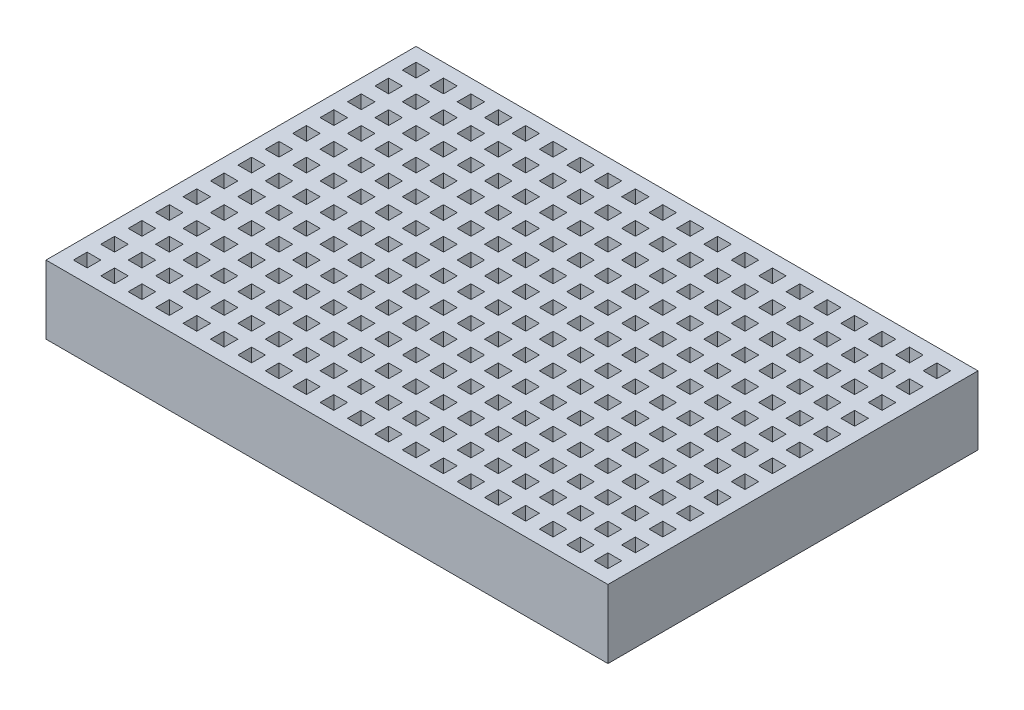
from build123d import *

# Parameters (mm, degrees)
SKETCH1_W           = 82
SKETCH1_H           = 54
BOSS_EXTRUDE2_DEPTH = 10
SKETCH3_W           = 2
SKETCH3_H           = 2
CUT_EXTRUDE1_DEPTH  = 5


with BuildPart() as part:
    # Sketch1 → Boss-Extrude2 (new body)
    with BuildSketch(Plane(origin=(0, 0, 0), x_dir=(1, 0, 0), z_dir=(0, 1, 0))):
        with Locations((-3.830449827, -8.982698962)):
            Rectangle(SKETCH1_W, SKETCH1_H)
    extrude(amount=BOSS_EXTRUDE2_DEPTH)

    # Sketch3 → Cut-Extrude1 (cut)
    with BuildSketch(Plane(origin=(0, 10, 0), x_dir=(1, 0, 0), z_dir=(0, 1, 0))):
        with Locations((-41.830449827, 15.017301038)):
            Rectangle(SKETCH3_W, SKETCH3_H)
        with Locations((-37.830449827, 15.017301038)):
            Rectangle(SKETCH3_W, SKETCH3_H)
        with Locations((-33.830449827, 15.017301038)):
            Rectangle(SKETCH3_W, SKETCH3_H)
        with Locations((-29.830449827, 15.017301038)):
            Rectangle(SKETCH3_W, SKETCH3_H)
        with Locations((-25.830449827, 15.017301038)):
            Rectangle(SKETCH3_W, SKETCH3_H)
        with Locations((-21.830449827, 15.017301038)):
            Rectangle(SKETCH3_W, SKETCH3_H)
        with Locations((-17.830449827, 15.017301038)):
            Rectangle(SKETCH3_W, SKETCH3_H)
        with Locations((-13.830449827, 15.017301038)):
            Rectangle(SKETCH3_W, SKETCH3_H)
        with Locations((-9.830449827, 15.017301038)):
            Rectangle(SKETCH3_W, SKETCH3_H)
        with Locations((-5.830449827, 15.017301038)):
            Rectangle(SKETCH3_W, SKETCH3_H)
        with Locations((-1.830449827, 15.017301038)):
            Rectangle(SKETCH3_W, SKETCH3_H)
        with Locations((2.169550173, 15.017301038)):
            Rectangle(SKETCH3_W, SKETCH3_H)
        with Locations((6.169550173, 15.017301038)):
            Rectangle(SKETCH3_W, SKETCH3_H)
        with Locations((10.169550173, 15.017301038)):
            Rectangle(SKETCH3_W, SKETCH3_H)
        with Locations((14.169550173, 15.017301038)):
            Rectangle(SKETCH3_W, SKETCH3_H)
        with Locations((18.169550173, 15.017301038)):
            Rectangle(SKETCH3_W, SKETCH3_H)
        with Locations((22.169550173, 15.017301038)):
            Rectangle(SKETCH3_W, SKETCH3_H)
        with Locations((26.169550173, 15.017301038)):
            Rectangle(SKETCH3_W, SKETCH3_H)
        with Locations((30.169550173, 15.017301038)):
            Rectangle(SKETCH3_W, SKETCH3_H)
        with Locations((34.169550173, 15.017301038)):
            Rectangle(SKETCH3_W, SKETCH3_H)
        with Locations((-37.830449827, 11.017301038)):
            Rectangle(SKETCH3_W, SKETCH3_H)
        with Locations((-33.830449827, 11.017301038)):
            Rectangle(SKETCH3_W, SKETCH3_H)
        with Locations((-29.830449827, 11.017301038)):
            Rectangle(SKETCH3_W, SKETCH3_H)
        with Locations((-25.830449827, 11.017301038)):
            Rectangle(SKETCH3_W, SKETCH3_H)
        with Locations((-21.830449827, 11.017301038)):
            Rectangle(SKETCH3_W, SKETCH3_H)
        with Locations((-17.830449827, 11.017301038)):
            Rectangle(SKETCH3_W, SKETCH3_H)
        with Locations((-13.830449827, 11.017301038)):
            Rectangle(SKETCH3_W, SKETCH3_H)
        with Locations((-9.830449827, 11.017301038)):
            Rectangle(SKETCH3_W, SKETCH3_H)
        with Locations((-5.830449827, 11.017301038)):
            Rectangle(SKETCH3_W, SKETCH3_H)
        with Locations((-1.830449827, 11.017301038)):
            Rectangle(SKETCH3_W, SKETCH3_H)
        with Locations((2.169550173, 11.017301038)):
            Rectangle(SKETCH3_W, SKETCH3_H)
        with Locations((6.169550173, 11.017301038)):
            Rectangle(SKETCH3_W, SKETCH3_H)
        with Locations((10.169550173, 11.017301038)):
            Rectangle(SKETCH3_W, SKETCH3_H)
        with Locations((14.169550173, 11.017301038)):
            Rectangle(SKETCH3_W, SKETCH3_H)
        with Locations((18.169550173, 11.017301038)):
            Rectangle(SKETCH3_W, SKETCH3_H)
        with Locations((22.169550173, 11.017301038)):
            Rectangle(SKETCH3_W, SKETCH3_H)
        with Locations((26.169550173, 11.017301038)):
            Rectangle(SKETCH3_W, SKETCH3_H)
        with Locations((30.169550173, 11.017301038)):
            Rectangle(SKETCH3_W, SKETCH3_H)
        with Locations((34.169550173, 11.017301038)):
            Rectangle(SKETCH3_W, SKETCH3_H)
        with Locations((-37.830449827, 7.017301038)):
            Rectangle(SKETCH3_W, SKETCH3_H)
        with Locations((-33.830449827, 7.017301038)):
            Rectangle(SKETCH3_W, SKETCH3_H)
        with Locations((-29.830449827, 7.017301038)):
            Rectangle(SKETCH3_W, SKETCH3_H)
        with Locations((-25.830449827, 7.017301038)):
            Rectangle(SKETCH3_W, SKETCH3_H)
        with Locations((-21.830449827, 7.017301038)):
            Rectangle(SKETCH3_W, SKETCH3_H)
        with Locations((-17.830449827, 7.017301038)):
            Rectangle(SKETCH3_W, SKETCH3_H)
        with Locations((-13.830449827, 7.017301038)):
            Rectangle(SKETCH3_W, SKETCH3_H)
        with Locations((-9.830449827, 7.017301038)):
            Rectangle(SKETCH3_W, SKETCH3_H)
        with Locations((-5.830449827, 7.017301038)):
            Rectangle(SKETCH3_W, SKETCH3_H)
        with Locations((-1.830449827, 7.017301038)):
            Rectangle(SKETCH3_W, SKETCH3_H)
        with Locations((2.169550173, 7.017301038)):
            Rectangle(SKETCH3_W, SKETCH3_H)
        with Locations((6.169550173, 7.017301038)):
            Rectangle(SKETCH3_W, SKETCH3_H)
        with Locations((10.169550173, 7.017301038)):
            Rectangle(SKETCH3_W, SKETCH3_H)
        with Locations((14.169550173, 7.017301038)):
            Rectangle(SKETCH3_W, SKETCH3_H)
        with Locations((18.169550173, 7.017301038)):
            Rectangle(SKETCH3_W, SKETCH3_H)
        with Locations((22.169550173, 7.017301038)):
            Rectangle(SKETCH3_W, SKETCH3_H)
        with Locations((26.169550173, 7.017301038)):
            Rectangle(SKETCH3_W, SKETCH3_H)
        with Locations((30.169550173, 7.017301038)):
            Rectangle(SKETCH3_W, SKETCH3_H)
        with Locations((34.169550173, 7.017301038)):
            Rectangle(SKETCH3_W, SKETCH3_H)
        with Locations((-37.830449827, 3.017301038)):
            Rectangle(SKETCH3_W, SKETCH3_H)
        with Locations((-33.830449827, 3.017301038)):
            Rectangle(SKETCH3_W, SKETCH3_H)
        with Locations((-29.830449827, 3.017301038)):
            Rectangle(SKETCH3_W, SKETCH3_H)
        with Locations((-25.830449827, 3.017301038)):
            Rectangle(SKETCH3_W, SKETCH3_H)
        with Locations((-21.830449827, 3.017301038)):
            Rectangle(SKETCH3_W, SKETCH3_H)
        with Locations((-17.830449827, 3.017301038)):
            Rectangle(SKETCH3_W, SKETCH3_H)
        with Locations((-13.830449827, 3.017301038)):
            Rectangle(SKETCH3_W, SKETCH3_H)
        with Locations((-9.830449827, 3.017301038)):
            Rectangle(SKETCH3_W, SKETCH3_H)
        with Locations((-5.830449827, 3.017301038)):
            Rectangle(SKETCH3_W, SKETCH3_H)
        with Locations((-1.830449827, 3.017301038)):
            Rectangle(SKETCH3_W, SKETCH3_H)
        with Locations((2.169550173, 3.017301038)):
            Rectangle(SKETCH3_W, SKETCH3_H)
        with Locations((6.169550173, 3.017301038)):
            Rectangle(SKETCH3_W, SKETCH3_H)
        with Locations((10.169550173, 3.017301038)):
            Rectangle(SKETCH3_W, SKETCH3_H)
        with Locations((14.169550173, 3.017301038)):
            Rectangle(SKETCH3_W, SKETCH3_H)
        with Locations((18.169550173, 3.017301038)):
            Rectangle(SKETCH3_W, SKETCH3_H)
        with Locations((22.169550173, 3.017301038)):
            Rectangle(SKETCH3_W, SKETCH3_H)
        with Locations((26.169550173, 3.017301038)):
            Rectangle(SKETCH3_W, SKETCH3_H)
        with Locations((30.169550173, 3.017301038)):
            Rectangle(SKETCH3_W, SKETCH3_H)
        with Locations((34.169550173, 3.017301038)):
            Rectangle(SKETCH3_W, SKETCH3_H)
        with Locations((-37.830449827, -0.982698962)):
            Rectangle(SKETCH3_W, SKETCH3_H)
        with Locations((-33.830449827, -0.982698962)):
            Rectangle(SKETCH3_W, SKETCH3_H)
        with Locations((-29.830449827, -0.982698962)):
            Rectangle(SKETCH3_W, SKETCH3_H)
        with Locations((-25.830449827, -0.982698962)):
            Rectangle(SKETCH3_W, SKETCH3_H)
        with Locations((-21.830449827, -0.982698962)):
            Rectangle(SKETCH3_W, SKETCH3_H)
        with Locations((-17.830449827, -0.982698962)):
            Rectangle(SKETCH3_W, SKETCH3_H)
        with Locations((-13.830449827, -0.982698962)):
            Rectangle(SKETCH3_W, SKETCH3_H)
        with Locations((-9.830449827, -0.982698962)):
            Rectangle(SKETCH3_W, SKETCH3_H)
        with Locations((-5.830449827, -0.982698962)):
            Rectangle(SKETCH3_W, SKETCH3_H)
        with Locations((-1.830449827, -0.982698962)):
            Rectangle(SKETCH3_W, SKETCH3_H)
        with Locations((2.169550173, -0.982698962)):
            Rectangle(SKETCH3_W, SKETCH3_H)
        with Locations((6.169550173, -0.982698962)):
            Rectangle(SKETCH3_W, SKETCH3_H)
        with Locations((10.169550173, -0.982698962)):
            Rectangle(SKETCH3_W, SKETCH3_H)
        with Locations((14.169550173, -0.982698962)):
            Rectangle(SKETCH3_W, SKETCH3_H)
        with Locations((18.169550173, -0.982698962)):
            Rectangle(SKETCH3_W, SKETCH3_H)
        with Locations((22.169550173, -0.982698962)):
            Rectangle(SKETCH3_W, SKETCH3_H)
        with Locations((26.169550173, -0.982698962)):
            Rectangle(SKETCH3_W, SKETCH3_H)
        with Locations((30.169550173, -0.982698962)):
            Rectangle(SKETCH3_W, SKETCH3_H)
        with Locations((34.169550173, -0.982698962)):
            Rectangle(SKETCH3_W, SKETCH3_H)
        with Locations((-37.830449827, -4.982698962)):
            Rectangle(SKETCH3_W, SKETCH3_H)
        with Locations((-33.830449827, -4.982698962)):
            Rectangle(SKETCH3_W, SKETCH3_H)
        with Locations((-29.830449827, -4.982698962)):
            Rectangle(SKETCH3_W, SKETCH3_H)
        with Locations((-25.830449827, -4.982698962)):
            Rectangle(SKETCH3_W, SKETCH3_H)
        with Locations((-21.830449827, -4.982698962)):
            Rectangle(SKETCH3_W, SKETCH3_H)
        with Locations((-17.830449827, -4.982698962)):
            Rectangle(SKETCH3_W, SKETCH3_H)
        with Locations((-13.830449827, -4.982698962)):
            Rectangle(SKETCH3_W, SKETCH3_H)
        with Locations((-9.830449827, -4.982698962)):
            Rectangle(SKETCH3_W, SKETCH3_H)
        with Locations((-5.830449827, -4.982698962)):
            Rectangle(SKETCH3_W, SKETCH3_H)
        with Locations((-1.830449827, -4.982698962)):
            Rectangle(SKETCH3_W, SKETCH3_H)
        with Locations((2.169550173, -4.982698962)):
            Rectangle(SKETCH3_W, SKETCH3_H)
        with Locations((6.169550173, -4.982698962)):
            Rectangle(SKETCH3_W, SKETCH3_H)
        with Locations((10.169550173, -4.982698962)):
            Rectangle(SKETCH3_W, SKETCH3_H)
        with Locations((14.169550173, -4.982698962)):
            Rectangle(SKETCH3_W, SKETCH3_H)
        with Locations((18.169550173, -4.982698962)):
            Rectangle(SKETCH3_W, SKETCH3_H)
        with Locations((22.169550173, -4.982698962)):
            Rectangle(SKETCH3_W, SKETCH3_H)
        with Locations((26.169550173, -4.982698962)):
            Rectangle(SKETCH3_W, SKETCH3_H)
        with Locations((30.169550173, -4.982698962)):
            Rectangle(SKETCH3_W, SKETCH3_H)
        with Locations((34.169550173, -4.982698962)):
            Rectangle(SKETCH3_W, SKETCH3_H)
        with Locations((-37.830449827, -8.982698962)):
            Rectangle(SKETCH3_W, SKETCH3_H)
        with Locations((-33.830449827, -8.982698962)):
            Rectangle(SKETCH3_W, SKETCH3_H)
        with Locations((-29.830449827, -8.982698962)):
            Rectangle(SKETCH3_W, SKETCH3_H)
        with Locations((-25.830449827, -8.982698962)):
            Rectangle(SKETCH3_W, SKETCH3_H)
        with Locations((-21.830449827, -8.982698962)):
            Rectangle(SKETCH3_W, SKETCH3_H)
        with Locations((-17.830449827, -8.982698962)):
            Rectangle(SKETCH3_W, SKETCH3_H)
        with Locations((-13.830449827, -8.982698962)):
            Rectangle(SKETCH3_W, SKETCH3_H)
        with Locations((-9.830449827, -8.982698962)):
            Rectangle(SKETCH3_W, SKETCH3_H)
        with Locations((-5.830449827, -8.982698962)):
            Rectangle(SKETCH3_W, SKETCH3_H)
        with Locations((-1.830449827, -8.982698962)):
            Rectangle(SKETCH3_W, SKETCH3_H)
        with Locations((2.169550173, -8.982698962)):
            Rectangle(SKETCH3_W, SKETCH3_H)
        with Locations((6.169550173, -8.982698962)):
            Rectangle(SKETCH3_W, SKETCH3_H)
        with Locations((10.169550173, -8.982698962)):
            Rectangle(SKETCH3_W, SKETCH3_H)
        with Locations((14.169550173, -8.982698962)):
            Rectangle(SKETCH3_W, SKETCH3_H)
        with Locations((18.169550173, -8.982698962)):
            Rectangle(SKETCH3_W, SKETCH3_H)
        with Locations((22.169550173, -8.982698962)):
            Rectangle(SKETCH3_W, SKETCH3_H)
        with Locations((26.169550173, -8.982698962)):
            Rectangle(SKETCH3_W, SKETCH3_H)
        with Locations((30.169550173, -8.982698962)):
            Rectangle(SKETCH3_W, SKETCH3_H)
        with Locations((34.169550173, -8.982698962)):
            Rectangle(SKETCH3_W, SKETCH3_H)
        with Locations((-37.830449827, -12.982698962)):
            Rectangle(SKETCH3_W, SKETCH3_H)
        with Locations((-33.830449827, -12.982698962)):
            Rectangle(SKETCH3_W, SKETCH3_H)
        with Locations((-29.830449827, -12.982698962)):
            Rectangle(SKETCH3_W, SKETCH3_H)
        with Locations((-25.830449827, -12.982698962)):
            Rectangle(SKETCH3_W, SKETCH3_H)
        with Locations((-21.830449827, -12.982698962)):
            Rectangle(SKETCH3_W, SKETCH3_H)
        with Locations((-17.830449827, -12.982698962)):
            Rectangle(SKETCH3_W, SKETCH3_H)
        with Locations((-13.830449827, -12.982698962)):
            Rectangle(SKETCH3_W, SKETCH3_H)
        with Locations((-9.830449827, -12.982698962)):
            Rectangle(SKETCH3_W, SKETCH3_H)
        with Locations((-5.830449827, -12.982698962)):
            Rectangle(SKETCH3_W, SKETCH3_H)
        with Locations((-1.830449827, -12.982698962)):
            Rectangle(SKETCH3_W, SKETCH3_H)
        with Locations((2.169550173, -12.982698962)):
            Rectangle(SKETCH3_W, SKETCH3_H)
        with Locations((6.169550173, -12.982698962)):
            Rectangle(SKETCH3_W, SKETCH3_H)
        with Locations((10.169550173, -12.982698962)):
            Rectangle(SKETCH3_W, SKETCH3_H)
        with Locations((14.169550173, -12.982698962)):
            Rectangle(SKETCH3_W, SKETCH3_H)
        with Locations((18.169550173, -12.982698962)):
            Rectangle(SKETCH3_W, SKETCH3_H)
        with Locations((22.169550173, -12.982698962)):
            Rectangle(SKETCH3_W, SKETCH3_H)
        with Locations((26.169550173, -12.982698962)):
            Rectangle(SKETCH3_W, SKETCH3_H)
        with Locations((30.169550173, -12.982698962)):
            Rectangle(SKETCH3_W, SKETCH3_H)
        with Locations((34.169550173, -12.982698962)):
            Rectangle(SKETCH3_W, SKETCH3_H)
        with Locations((-37.830449827, -16.982698962)):
            Rectangle(SKETCH3_W, SKETCH3_H)
        with Locations((-33.830449827, -16.982698962)):
            Rectangle(SKETCH3_W, SKETCH3_H)
        with Locations((-29.830449827, -16.982698962)):
            Rectangle(SKETCH3_W, SKETCH3_H)
        with Locations((-25.830449827, -16.982698962)):
            Rectangle(SKETCH3_W, SKETCH3_H)
        with Locations((-21.830449827, -16.982698962)):
            Rectangle(SKETCH3_W, SKETCH3_H)
        with Locations((-17.830449827, -16.982698962)):
            Rectangle(SKETCH3_W, SKETCH3_H)
        with Locations((-13.830449827, -16.982698962)):
            Rectangle(SKETCH3_W, SKETCH3_H)
        with Locations((-9.830449827, -16.982698962)):
            Rectangle(SKETCH3_W, SKETCH3_H)
        with Locations((-5.830449827, -16.982698962)):
            Rectangle(SKETCH3_W, SKETCH3_H)
        with Locations((-1.830449827, -16.982698962)):
            Rectangle(SKETCH3_W, SKETCH3_H)
        with Locations((2.169550173, -16.982698962)):
            Rectangle(SKETCH3_W, SKETCH3_H)
        with Locations((6.169550173, -16.982698962)):
            Rectangle(SKETCH3_W, SKETCH3_H)
        with Locations((10.169550173, -16.982698962)):
            Rectangle(SKETCH3_W, SKETCH3_H)
        with Locations((14.169550173, -16.982698962)):
            Rectangle(SKETCH3_W, SKETCH3_H)
        with Locations((18.169550173, -16.982698962)):
            Rectangle(SKETCH3_W, SKETCH3_H)
        with Locations((22.169550173, -16.982698962)):
            Rectangle(SKETCH3_W, SKETCH3_H)
        with Locations((26.169550173, -16.982698962)):
            Rectangle(SKETCH3_W, SKETCH3_H)
        with Locations((30.169550173, -16.982698962)):
            Rectangle(SKETCH3_W, SKETCH3_H)
        with Locations((34.169550173, -16.982698962)):
            Rectangle(SKETCH3_W, SKETCH3_H)
        with Locations((-37.830449827, -20.982698962)):
            Rectangle(SKETCH3_W, SKETCH3_H)
        with Locations((-33.830449827, -20.982698962)):
            Rectangle(SKETCH3_W, SKETCH3_H)
        with Locations((-29.830449827, -20.982698962)):
            Rectangle(SKETCH3_W, SKETCH3_H)
        with Locations((-25.830449827, -20.982698962)):
            Rectangle(SKETCH3_W, SKETCH3_H)
        with Locations((-21.830449827, -20.982698962)):
            Rectangle(SKETCH3_W, SKETCH3_H)
        with Locations((-17.830449827, -20.982698962)):
            Rectangle(SKETCH3_W, SKETCH3_H)
        with Locations((-13.830449827, -20.982698962)):
            Rectangle(SKETCH3_W, SKETCH3_H)
        with Locations((-9.830449827, -20.982698962)):
            Rectangle(SKETCH3_W, SKETCH3_H)
        with Locations((-5.830449827, -20.982698962)):
            Rectangle(SKETCH3_W, SKETCH3_H)
        with Locations((-1.830449827, -20.982698962)):
            Rectangle(SKETCH3_W, SKETCH3_H)
        with Locations((2.169550173, -20.982698962)):
            Rectangle(SKETCH3_W, SKETCH3_H)
        with Locations((6.169550173, -20.982698962)):
            Rectangle(SKETCH3_W, SKETCH3_H)
        with Locations((10.169550173, -20.982698962)):
            Rectangle(SKETCH3_W, SKETCH3_H)
        with Locations((14.169550173, -20.982698962)):
            Rectangle(SKETCH3_W, SKETCH3_H)
        with Locations((18.169550173, -20.982698962)):
            Rectangle(SKETCH3_W, SKETCH3_H)
        with Locations((22.169550173, -20.982698962)):
            Rectangle(SKETCH3_W, SKETCH3_H)
        with Locations((26.169550173, -20.982698962)):
            Rectangle(SKETCH3_W, SKETCH3_H)
        with Locations((30.169550173, -20.982698962)):
            Rectangle(SKETCH3_W, SKETCH3_H)
        with Locations((34.169550173, -20.982698962)):
            Rectangle(SKETCH3_W, SKETCH3_H)
        with Locations((-37.830449827, -24.982698962)):
            Rectangle(SKETCH3_W, SKETCH3_H)
        with Locations((-33.830449827, -24.982698962)):
            Rectangle(SKETCH3_W, SKETCH3_H)
        with Locations((-29.830449827, -24.982698962)):
            Rectangle(SKETCH3_W, SKETCH3_H)
        with Locations((-25.830449827, -24.982698962)):
            Rectangle(SKETCH3_W, SKETCH3_H)
        with Locations((-21.830449827, -24.982698962)):
            Rectangle(SKETCH3_W, SKETCH3_H)
        with Locations((-17.830449827, -24.982698962)):
            Rectangle(SKETCH3_W, SKETCH3_H)
        with Locations((-13.830449827, -24.982698962)):
            Rectangle(SKETCH3_W, SKETCH3_H)
        with Locations((-9.830449827, -24.982698962)):
            Rectangle(SKETCH3_W, SKETCH3_H)
        with Locations((-5.830449827, -24.982698962)):
            Rectangle(SKETCH3_W, SKETCH3_H)
        with Locations((-1.830449827, -24.982698962)):
            Rectangle(SKETCH3_W, SKETCH3_H)
        with Locations((2.169550173, -24.982698962)):
            Rectangle(SKETCH3_W, SKETCH3_H)
        with Locations((6.169550173, -24.982698962)):
            Rectangle(SKETCH3_W, SKETCH3_H)
        with Locations((10.169550173, -24.982698962)):
            Rectangle(SKETCH3_W, SKETCH3_H)
        with Locations((14.169550173, -24.982698962)):
            Rectangle(SKETCH3_W, SKETCH3_H)
        with Locations((18.169550173, -24.982698962)):
            Rectangle(SKETCH3_W, SKETCH3_H)
        with Locations((22.169550173, -24.982698962)):
            Rectangle(SKETCH3_W, SKETCH3_H)
        with Locations((26.169550173, -24.982698962)):
            Rectangle(SKETCH3_W, SKETCH3_H)
        with Locations((30.169550173, -24.982698962)):
            Rectangle(SKETCH3_W, SKETCH3_H)
        with Locations((34.169550173, -24.982698962)):
            Rectangle(SKETCH3_W, SKETCH3_H)
        with Locations((-37.830449827, -28.982698962)):
            Rectangle(SKETCH3_W, SKETCH3_H)
        with Locations((-33.830449827, -28.982698962)):
            Rectangle(SKETCH3_W, SKETCH3_H)
        with Locations((-29.830449827, -28.982698962)):
            Rectangle(SKETCH3_W, SKETCH3_H)
        with Locations((-25.830449827, -28.982698962)):
            Rectangle(SKETCH3_W, SKETCH3_H)
        with Locations((-21.830449827, -28.982698962)):
            Rectangle(SKETCH3_W, SKETCH3_H)
        with Locations((-17.830449827, -28.982698962)):
            Rectangle(SKETCH3_W, SKETCH3_H)
        with Locations((-13.830449827, -28.982698962)):
            Rectangle(SKETCH3_W, SKETCH3_H)
        with Locations((-9.830449827, -28.982698962)):
            Rectangle(SKETCH3_W, SKETCH3_H)
        with Locations((-5.830449827, -28.982698962)):
            Rectangle(SKETCH3_W, SKETCH3_H)
        with Locations((-1.830449827, -28.982698962)):
            Rectangle(SKETCH3_W, SKETCH3_H)
        with Locations((2.169550173, -28.982698962)):
            Rectangle(SKETCH3_W, SKETCH3_H)
        with Locations((6.169550173, -28.982698962)):
            Rectangle(SKETCH3_W, SKETCH3_H)
        with Locations((10.169550173, -28.982698962)):
            Rectangle(SKETCH3_W, SKETCH3_H)
        with Locations((14.169550173, -28.982698962)):
            Rectangle(SKETCH3_W, SKETCH3_H)
        with Locations((18.169550173, -28.982698962)):
            Rectangle(SKETCH3_W, SKETCH3_H)
        with Locations((22.169550173, -28.982698962)):
            Rectangle(SKETCH3_W, SKETCH3_H)
        with Locations((26.169550173, -28.982698962)):
            Rectangle(SKETCH3_W, SKETCH3_H)
        with Locations((30.169550173, -28.982698962)):
            Rectangle(SKETCH3_W, SKETCH3_H)
        with Locations((34.169550173, -28.982698962)):
            Rectangle(SKETCH3_W, SKETCH3_H)
        with Locations((-37.830449827, -32.982698962)):
            Rectangle(SKETCH3_W, SKETCH3_H)
        with Locations((-33.830449827, -32.982698962)):
            Rectangle(SKETCH3_W, SKETCH3_H)
        with Locations((-29.830449827, -32.982698962)):
            Rectangle(SKETCH3_W, SKETCH3_H)
        with Locations((-25.830449827, -32.982698962)):
            Rectangle(SKETCH3_W, SKETCH3_H)
        with Locations((-21.830449827, -32.982698962)):
            Rectangle(SKETCH3_W, SKETCH3_H)
        with Locations((-17.830449827, -32.982698962)):
            Rectangle(SKETCH3_W, SKETCH3_H)
        with Locations((-13.830449827, -32.982698962)):
            Rectangle(SKETCH3_W, SKETCH3_H)
        with Locations((-9.830449827, -32.982698962)):
            Rectangle(SKETCH3_W, SKETCH3_H)
        with Locations((-5.830449827, -32.982698962)):
            Rectangle(SKETCH3_W, SKETCH3_H)
        with Locations((-1.830449827, -32.982698962)):
            Rectangle(SKETCH3_W, SKETCH3_H)
        with Locations((2.169550173, -32.982698962)):
            Rectangle(SKETCH3_W, SKETCH3_H)
        with Locations((6.169550173, -32.982698962)):
            Rectangle(SKETCH3_W, SKETCH3_H)
        with Locations((10.169550173, -32.982698962)):
            Rectangle(SKETCH3_W, SKETCH3_H)
        with Locations((14.169550173, -32.982698962)):
            Rectangle(SKETCH3_W, SKETCH3_H)
        with Locations((18.169550173, -32.982698962)):
            Rectangle(SKETCH3_W, SKETCH3_H)
        with Locations((22.169550173, -32.982698962)):
            Rectangle(SKETCH3_W, SKETCH3_H)
        with Locations((26.169550173, -32.982698962)):
            Rectangle(SKETCH3_W, SKETCH3_H)
        with Locations((30.169550173, -32.982698962)):
            Rectangle(SKETCH3_W, SKETCH3_H)
        with Locations((34.169550173, -32.982698962)):
            Rectangle(SKETCH3_W, SKETCH3_H)
        with Locations((-41.830449827, 11.017301038)):
            Rectangle(SKETCH3_W, SKETCH3_H)
        with Locations((-41.830449827, 7.017301038)):
            Rectangle(SKETCH3_W, SKETCH3_H)
        with Locations((-41.830449827, 3.017301038)):
            Rectangle(SKETCH3_W, SKETCH3_H)
        with Locations((-41.830449827, -0.982698962)):
            Rectangle(SKETCH3_W, SKETCH3_H)
        with Locations((-41.830449827, -4.982698962)):
            Rectangle(SKETCH3_W, SKETCH3_H)
        with Locations((-41.830449827, -8.982698962)):
            Rectangle(SKETCH3_W, SKETCH3_H)
        with Locations((-41.830449827, -12.982698962)):
            Rectangle(SKETCH3_W, SKETCH3_H)
        with Locations((-41.830449827, -16.982698962)):
            Rectangle(SKETCH3_W, SKETCH3_H)
        with Locations((-41.830449827, -20.982698962)):
            Rectangle(SKETCH3_W, SKETCH3_H)
        with Locations((-41.830449827, -24.982698962)):
            Rectangle(SKETCH3_W, SKETCH3_H)
        with Locations((-41.830449827, -28.982698962)):
            Rectangle(SKETCH3_W, SKETCH3_H)
        with Locations((-41.830449827, -32.982698962)):
            Rectangle(SKETCH3_W, SKETCH3_H)
    extrude(amount=-CUT_EXTRUDE1_DEPTH, mode=Mode.SUBTRACT)


solid = part.part
